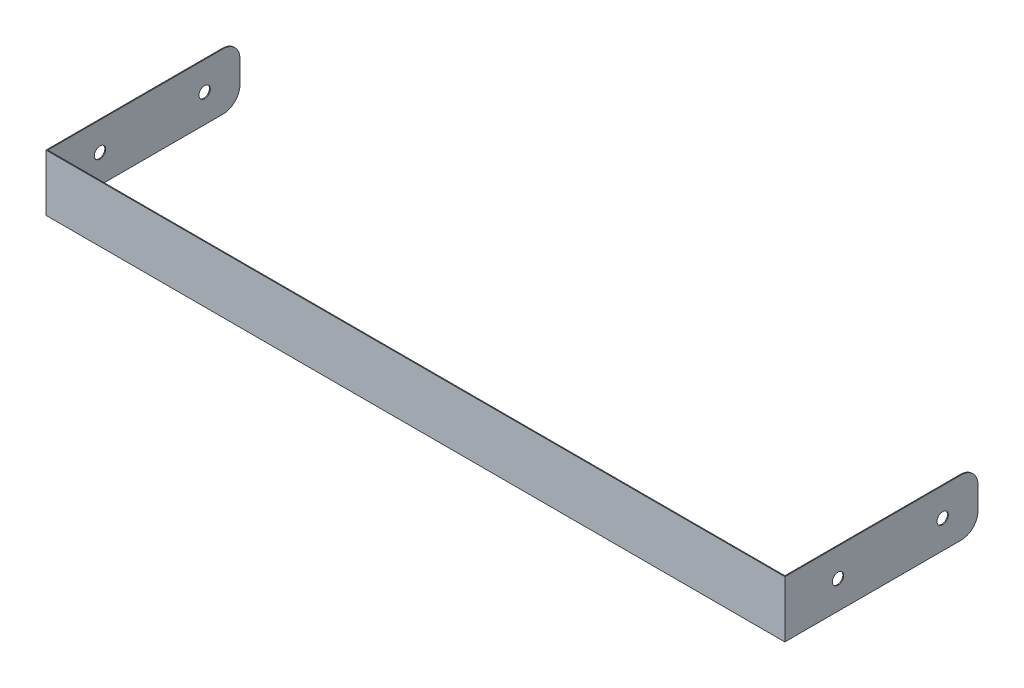
from build123d import *

# Parameters (mm, degrees)
BOSS_EXTRUDE1_DEPTH = 10
FILLET1_R           = 3
SKETCH2_R           = 1
CUT_EXTRUDE1_DEPTH  = 130.65


with BuildPart() as part:
    # Sketch1 → Boss-Extrude1 (new body)
    with BuildSketch(Plane(origin=(0, 0, 0), x_dir=(1, 0, 0), z_dir=(0, 1, 0))):
        Polygon((0, 0), (0, -34.15), (-130.65, -34.15), (-130.65, 0), (-130.5, 0), (-130.5, -34), (-0.15, -34), (-0.15, 0), align=None)
    extrude(amount=BOSS_EXTRUDE1_DEPTH)

    # Fillet1
    fillet1_edges = [part.edges().sort_by_distance(p)[0] for p in [
        (-0.075, 10, 0),
        (-130.575, 10, 0),
        (-130.575, 0, 0),
        (-0.075, 0, 0),
    ]]
    fillet(fillet1_edges, radius=FILLET1_R)

    # Sketch2 → Cut-Extrude1 (cut)
    with BuildSketch(Plane(origin=(0, 0, 0), x_dir=(0, 0, -1), z_dir=(1, 0, 0))):
        with Locations((-6.25, 5)):
            Circle(SKETCH2_R)
        with Locations((-24.75, 5)):
            Circle(SKETCH2_R)
    extrude(amount=-CUT_EXTRUDE1_DEPTH, mode=Mode.SUBTRACT)


solid = part.part
